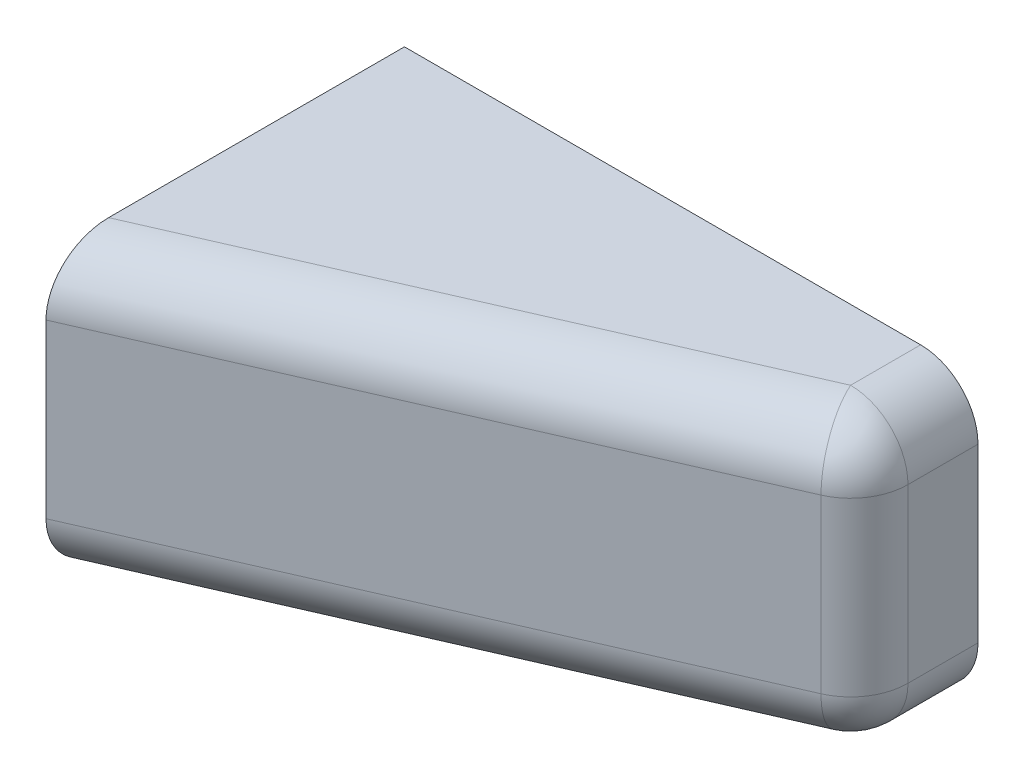
from build123d import *

# Parameters (mm, degrees)
SKETCH1_W           = 40
SKETCH1_H           = 20
SKETCH1_R           = 1.6
BOSS_EXTRUDE1_DEPTH = 5
BOSS_EXTRUDE2_DEPTH = 2.5
BOSS_EXTRUDE3_DEPTH = 20
CUT_EXTRUDE1_DEPTH  = 2.5
CUT_EXTRUDE2_DEPTH  = 20
FILLET1_R           = 4
CHAMFER1_SIZE       = 1


with BuildPart() as part:
    # Sketch1 → Boss-Extrude1 (new body)
    with BuildSketch(Plane.XY):
        with Locations((20, 10)):
            Rectangle(SKETCH1_W, SKETCH1_H)
        with Locations((13, 10)):
            Circle(SKETCH1_R, mode=Mode.SUBTRACT)
        with Locations((34, 10)):
            Circle(SKETCH1_R, mode=Mode.SUBTRACT)
    extrude(amount=BOSS_EXTRUDE1_DEPTH)

    # Sketch3 → Boss-Extrude2 (add)
    with BuildSketch(Plane.XY.offset(5)):
        Polygon((35.58771324, 7.25), (36.38156986, 8.625), (37.175426481, 10), (36.38156986, 11.375), (35.58771324, 12.75), (0, 12.75), (0, 20), (40, 20), (40, 0), (0, 0), (0, 7.25), align=None)
    extrude(amount=BOSS_EXTRUDE2_DEPTH)

    # Sketch4 → Boss-Extrude3 (add, through all)
    with BuildSketch(Plane(origin=(0, 20, 0), x_dir=(1, 0, 0), z_dir=(0, 1, 0))):
        Polygon((40, -7.5), (0, -25), (0, -7.5), align=None)
    extrude(amount=-BOSS_EXTRUDE3_DEPTH)

    # Sketch6 → Cut-Extrude1 (cut)
    with BuildSketch(Plane.ZY):
        with BuildLine():
            Line((0, 10), (0, 6))
            Line((0, 6), (14, 6))
            ThreePointArc((14, 6), (18, 10), (14, 14))
            Line((14, 14), (0, 14))
            Line((0, 14), (0, 10))
        make_face()
    extrude(amount=-CUT_EXTRUDE1_DEPTH, mode=Mode.SUBTRACT)

    # Sketch7 → Cut-Extrude2 (cut)
    with BuildSketch(Plane(origin=(0, 0, 0), x_dir=(-1, 0, 0), z_dir=(0, 0, -1))):
        Polygon((-2.5, 14), (-2.5, 16), (-9.5, 16), (-9.5, 4), (-2.5, 4), (-2.5, 6), align=None)
    extrude(amount=-CUT_EXTRUDE2_DEPTH, mode=Mode.SUBTRACT)

    # Fillet1
    fillet1_edges = [part.edges().sort_by_distance(p)[0] for p in [
        (40, 10, 7.5),
        (20, 0, 16.25),
        (20, 20, 16.25),
        (40, 20, 3.75),
        (40, 0, 3.75),
    ]]
    fillet(fillet1_edges, radius=FILLET1_R)

    # Chamfer1
    chamfer1_edges = [part.edges().sort_by_distance(p)[0] for p in [
        (2.5, 14, 7),
        (2.5, 10, 18),
        (2.5, 6, 7),
        (9.5, 12.75, 6.25),
        (9.5, 7.25, 6.25),
        (2.5, 5, 0),
        (2.5, 15, 0),
        (6, 4, 0),
        (9.5, 10, 5),
        (9.5, 10, 7.5),
        (9.5, 10, 0),
        (6, 16, 0),
    ]]
    chamfer(chamfer1_edges, length=CHAMFER1_SIZE)


solid = part.part
